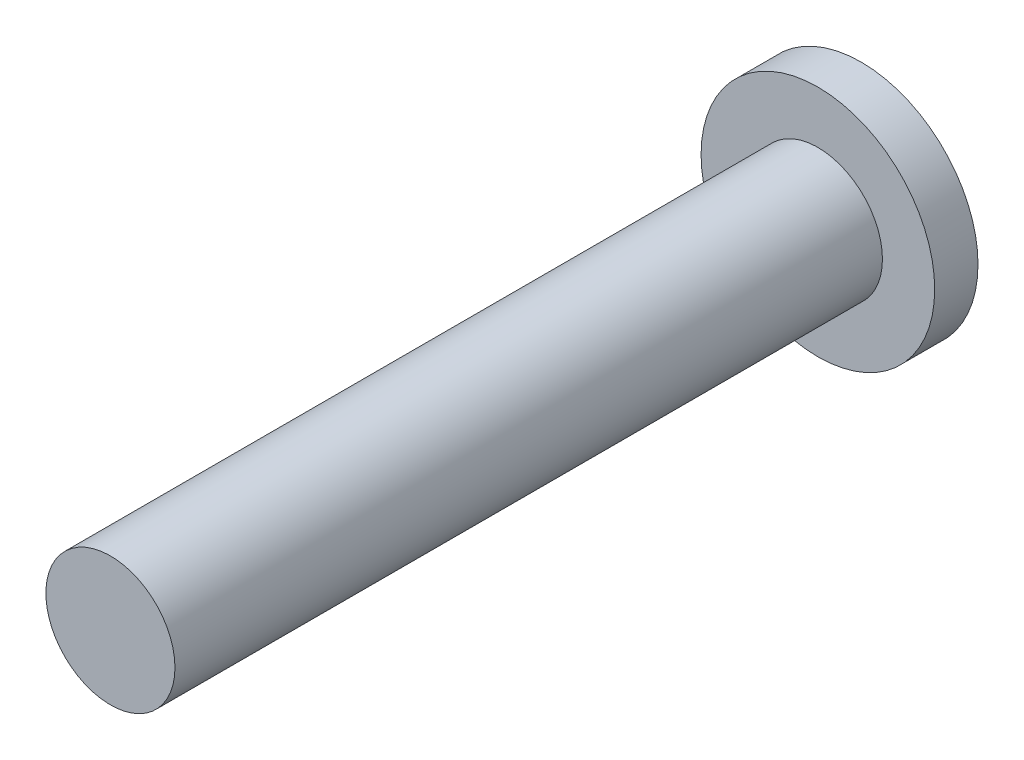
from build123d import *

# Parameters (mm, degrees)
SKETCH1_R           = 4.425
BOSS_EXTRUDE1_DEPTH = 1.64
SKETCH2_R           = 2.445
BOSS_EXTRUDE2_DEPTH = 26.8


with BuildPart() as part:
    # Sketch1 → Boss-Extrude1 (new body)
    with BuildSketch(Plane.XY):
        Circle(SKETCH1_R)
    extrude(amount=BOSS_EXTRUDE1_DEPTH)

    # Sketch2 → Boss-Extrude2 (add)
    with BuildSketch(Plane.XY.offset(1.64)):
        Circle(SKETCH2_R)
    extrude(amount=BOSS_EXTRUDE2_DEPTH)


solid = part.part
